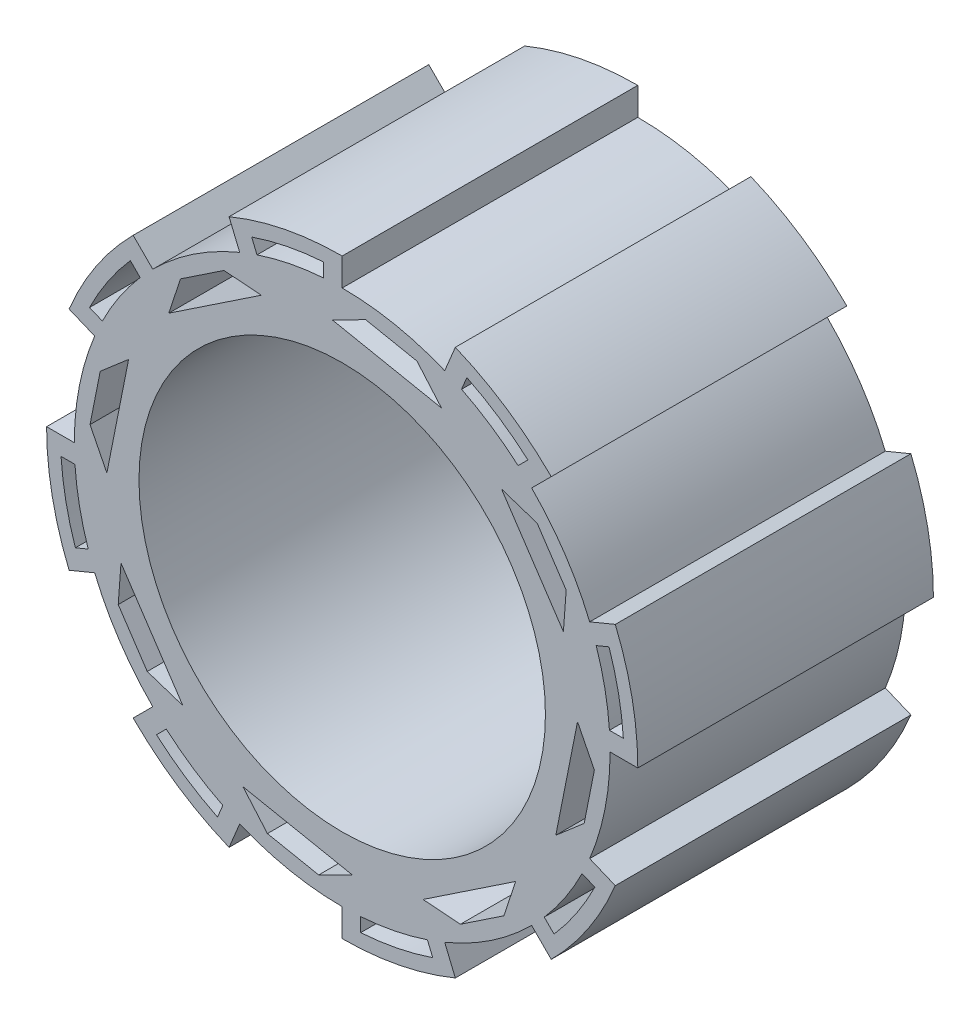
from build123d import *

# Parameters (mm, degrees)
BOSS_EXTRUDE1_DEPTH     = 80
SKETCH2_R               = 55
CUT_EXTRUDE1_DEPTH      = 67
CUT_EXTRUDE1_DEPTH_BACK = 127
CUT_EXTRUDE2_DEPTH      = 21
CUT_EXTRUDE2_DEPTH_BACK = 103
CUT_EXTRUDE3_DEPTH      = 36
CUT_EXTRUDE3_DEPTH_BACK = 105


with BuildPart() as part:
    # Base Drawing → Boss-Extrude1 (new body)
    with BuildSketch(Plane.XY):
        with BuildLine():
            Line((0, 72.5), (0, 80))
            ThreePointArc((0, 80), (-15.607225761, 78.462822432), (-30.614674589, 73.910362601))
            Line((-30.614674589, 73.910362601), (-27.744548846, 66.981266107))
            Line((-27.744548846, 66.981266107), (-25.632620818, 61.882620818))
            Line((-25.632620818, 61.882620818), (0, 0))
            Line((0, 0), (0, 72.5))
        make_face()
        with BuildLine():
            Line((-51.265241636, 51.265241636), (0, 0))
            Line((0, 0), (-25.632620818, 61.882620818))
            Line((-25.632620818, 61.882620818), (-27.744548846, 66.981266107))
            ThreePointArc((-27.744548846, 66.981266107), (-40.278841894, 60.281546892), (-51.265241636, 51.265241636))
        make_face()
        with BuildLine():
            Line((-61.882620818, 25.632620818), (0, 0))
            Line((0, 0), (-51.265241636, 51.265241636))
            Line((-51.265241636, 51.265241636), (-56.568542495, 56.568542495))
            ThreePointArc((-56.568542495, 56.568542495), (-66.517568984, 44.445618642), (-73.910362601, 30.614674589))
            Line((-73.910362601, 30.614674589), (-66.981266107, 27.744548846))
            Line((-66.981266107, 27.744548846), (-61.882620818, 25.632620818))
        make_face()
        with BuildLine():
            Line((-72.5, 0), (0, 0))
            Line((0, 0), (-61.882620818, 25.632620818))
            Line((-61.882620818, 25.632620818), (-66.981266107, 27.744548846))
            ThreePointArc((-66.981266107, 27.744548846), (-71.106932829, 14.144048346), (-72.5, 0))
        make_face()
        with BuildLine():
            Line((-61.882620818, -25.632620818), (0, 0))
            Line((0, 0), (-72.5, 0))
            Line((-72.5, 0), (-80, 0))
            ThreePointArc((-80, 0), (-78.462822432, -15.607225761), (-73.910362601, -30.614674589))
            Line((-73.910362601, -30.614674589), (-66.981266107, -27.744548846))
            Line((-66.981266107, -27.744548846), (-61.882620818, -25.632620818))
        make_face()
        with BuildLine():
            Line((-51.265241636, -51.265241636), (0, 0))
            Line((0, 0), (-61.882620818, -25.632620818))
            Line((-61.882620818, -25.632620818), (-66.981266107, -27.744548846))
            ThreePointArc((-66.981266107, -27.744548846), (-60.281546892, -40.278841894), (-51.265241636, -51.265241636))
        make_face()
        with BuildLine():
            Line((-25.632620818, -61.882620818), (0, 0))
            Line((0, 0), (-51.265241636, -51.265241636))
            Line((-51.265241636, -51.265241636), (-56.568542495, -56.568542495))
            ThreePointArc((-56.568542495, -56.568542495), (-44.445618642, -66.517568984), (-30.614674589, -73.910362601))
            Line((-30.614674589, -73.910362601), (-27.744548846, -66.981266107))
            Line((-27.744548846, -66.981266107), (-25.632620818, -61.882620818))
        make_face()
        with BuildLine():
            Line((0, -72.5), (0, 0))
            Line((0, 0), (-25.632620818, -61.882620818))
            Line((-25.632620818, -61.882620818), (-27.744548846, -66.981266107))
            ThreePointArc((-27.744548846, -66.981266107), (-14.144048346, -71.106932829), (0, -72.5))
        make_face()
        with BuildLine():
            Line((27.744548846, -66.981266107), (0, 0))
            Line((0, 0), (0, -72.5))
            Line((0, -72.5), (0, -80))
            ThreePointArc((0, -80), (15.607225761, -78.462822432), (30.614674589, -73.910362601))
            Line((30.614674589, -73.910362601), (27.744548846, -66.981266107))
        make_face()
        with BuildLine():
            Line((51.265241636, -51.265241636), (0, 0))
            Line((0, 0), (27.744548846, -66.981266107))
            ThreePointArc((27.744548846, -66.981266107), (40.278841894, -60.281546892), (51.265241636, -51.265241636))
        make_face()
        with BuildLine():
            Line((66.981266107, -27.744548846), (0, 0))
            Line((0, 0), (51.265241636, -51.265241636))
            Line((51.265241636, -51.265241636), (56.568542495, -56.568542495))
            ThreePointArc((56.568542495, -56.568542495), (66.517568984, -44.445618642), (73.910362601, -30.614674589))
            Line((73.910362601, -30.614674589), (66.981266107, -27.744548846))
        make_face()
        with BuildLine():
            Line((72.5, 0), (0, 0))
            Line((0, 0), (66.981266107, -27.744548846))
            ThreePointArc((66.981266107, -27.744548846), (71.106932829, -14.144048346), (72.5, 0))
        make_face()
        with BuildLine():
            Line((66.981266107, 27.744548846), (0, 0))
            Line((0, 0), (72.5, 0))
            Line((72.5, 0), (80, 0))
            ThreePointArc((80, 0), (78.462822432, 15.607225761), (73.910362601, 30.614674589))
            Line((73.910362601, 30.614674589), (66.981266107, 27.744548846))
        make_face()
        with BuildLine():
            Line((51.265241636, 51.265241636), (0, 0))
            Line((0, 0), (66.981266107, 27.744548846))
            ThreePointArc((66.981266107, 27.744548846), (60.281546892, 40.278841894), (51.265241636, 51.265241636))
        make_face()
        with BuildLine():
            Line((25.632620818, 61.882620818), (0, 0))
            Line((0, 0), (51.265241636, 51.265241636))
            Line((51.265241636, 51.265241636), (56.568542495, 56.568542495))
            ThreePointArc((56.568542495, 56.568542495), (44.445618642, 66.517568984), (30.614674589, 73.910362601))
            Line((30.614674589, 73.910362601), (27.744548846, 66.981266107))
            Line((27.744548846, 66.981266107), (25.632620818, 61.882620818))
        make_face()
        with BuildLine():
            ThreePointArc((27.744548846, 66.981266107), (14.144048346, 71.106932829), (0, 72.5))
            Line((0, 72.5), (0, 0))
            Line((0, 0), (25.632620818, 61.882620818))
            Line((25.632620818, 61.882620818), (27.744548846, 66.981266107))
        make_face()
    extrude(amount=BOSS_EXTRUDE1_DEPTH)

    # Sketch2 → Cut-Extrude1 (cut, two sides)
    with BuildSketch(Plane.XY.offset(80)) as cut_extrude1_sk:
        Circle(SKETCH2_R)
    extrude(amount=CUT_EXTRUDE1_DEPTH, mode=Mode.SUBTRACT)
    extrude(cut_extrude1_sk.sketch, amount=-CUT_EXTRUDE1_DEPTH_BACK, mode=Mode.SUBTRACT)

    # Sketch3 → Cut-Extrude2 (cut, two sides)
    with BuildSketch(Plane(origin=(0, 0, 0), x_dir=(-1, 0, 0), z_dir=(0, 0, -1))) as cut_extrude2_sk:
        with BuildLine():
            Line((-32.297887966, 64.908369514), (-32.363946509, 65.067848945))
            Line((-32.363946509, 65.067848945), (-33.156509848, 66.981266107))
            Line((-33.156509848, 66.981266107), (-33.736206807, 68.380778368))
            ThreePointArc((-33.736206807, 68.380778368), (-42.362230268, 63.399557938), (-50.265314136, 57.336381948))
            Line((-50.265314136, 57.336381948), (-49.203804332, 56.274872144))
            Line((-49.203804332, 56.274872144), (-47.72970773, 54.800775542))
            Line((-47.72970773, 54.800775542), (-47.607647458, 54.67871527))
            ThreePointArc((-47.607647458, 54.67871527), (-40.278841894, 60.281546892), (-32.297887966, 64.908369514))
        make_face()
        with BuildLine():
            Line((-68.735203838, 23.059092641), (-68.894683269, 23.125151184))
            Line((-68.894683269, 23.125151184), (-71.001371746, 23.997770123))
            Line((-71.001371746, 23.997770123), (-72.207612692, 24.497411482))
            ThreePointArc((-72.207612692, 24.497411482), (-74.784877631, 14.875637054), (-76.085888968, 5))
            Line((-76.085888968, 5), (-74.668691299, 5))
            Line((-74.668691299, 5), (-72.5, 5))
            Line((-72.5, 5), (-72.327380707, 5))
            ThreePointArc((-72.327380707, 5), (-71.106932829, 14.144048346), (-68.735203838, 23.059092641))
        make_face()
        with BuildLine():
            Line((-64.908369514, -32.297887966), (-65.067848945, -32.363946509))
            Line((-65.067848945, -32.363946509), (-66.981266107, -33.156509848))
            Line((-66.981266107, -33.156509848), (-68.363511265, -33.729054539))
            Line((-68.363511265, -33.729054539), (-68.380778368, -33.736206807))
            ThreePointArc((-68.380778368, -33.736206807), (-63.399557938, -42.362230268), (-57.336381948, -50.265314136))
            Line((-57.336381948, -50.265314136), (-56.25693439, -49.185866578))
            Line((-56.25693439, -49.185866578), (-54.800775542, -47.72970773))
            Line((-54.800775542, -47.72970773), (-54.67871527, -47.607647458))
            ThreePointArc((-54.67871527, -47.607647458), (-60.281546892, -40.278841894), (-64.908369514, -32.297887966))
        make_face()
        with BuildLine():
            ThreePointArc((-24.497411482, -72.207612692), (-14.875637054, -74.784877631), (-5, -76.085888968))
            Line((-5, -76.085888968), (-5, -75.365107954))
            Line((-5, -75.365107954), (-5, -74.464091379))
            Line((-5, -74.464091379), (-5, -72.5))
            Line((-5, -72.5), (-5, -72.327380707))
            ThreePointArc((-5, -72.327380707), (-14.144048346, -71.106932829), (-23.059092641, -68.735203838))
            Line((-23.059092641, -68.735203838), (-23.125151184, -68.894683269))
            Line((-23.125151184, -68.894683269), (-23.932515407, -70.843832926))
            Line((-23.932515407, -70.843832926), (-24.417934118, -72.015737361))
            Line((-24.417934118, -72.015737361), (-24.497411482, -72.207612692))
        make_face()
        with BuildLine():
            Line((48.47079588, -55.541863692), (47.72970773, -54.800775542))
            Line((47.72970773, -54.800775542), (47.607647458, -54.67871527))
            ThreePointArc((47.607647458, -54.67871527), (40.278841894, -60.281546892), (32.297887966, -64.908369514))
            Line((32.297887966, -64.908369514), (32.363946509, -65.067848945))
            Line((32.363946509, -65.067848945), (32.936166208, -66.449309504))
            Line((32.936166208, -66.449309504), (33.603941902, -68.061462639))
            Line((33.603941902, -68.061462639), (33.736206807, -68.380778368))
            ThreePointArc((33.736206807, -68.380778368), (42.362230268, -63.399557938), (50.265314136, -57.336381948))
            Line((50.265314136, -57.336381948), (48.47079588, -55.541863692))
        make_face()
        with BuildLine():
            Line((75.823779763, -5), (72.5, -5))
            Line((72.5, -5), (72.337295851, -5))
            Line((72.337295851, -5), (72.327380707, -5))
            ThreePointArc((72.327380707, -5), (71.106932829, -14.144048346), (68.735203838, -23.059092641))
            Line((68.735203838, -23.059092641), (68.894683269, -23.125151184))
            Line((68.894683269, -23.125151184), (69.253006962, -23.273573717))
            Line((69.253006962, -23.273573717), (70.382632906, -23.741480104))
            Line((70.382632906, -23.741480104), (72.207612692, -24.497411482))
            ThreePointArc((72.207612692, -24.497411482), (74.784877631, -14.875637054), (76.085888968, -5))
            Line((76.085888968, -5), (75.823779763, -5))
        make_face()
        with BuildLine():
            Line((56.184348869, 49.113281057), (54.800775542, 47.72970773))
            Line((54.800775542, 47.72970773), (54.679998373, 47.608930561))
            Line((54.679998373, 47.608930561), (54.67871527, 47.607647458))
            ThreePointArc((54.67871527, 47.607647458), (60.281546892, 40.278841894), (64.908369514, 32.297887966))
            Line((64.908369514, 32.297887966), (65.067848945, 32.363946509))
            Line((65.067848945, 32.363946509), (65.431620873, 32.514625775))
            Line((65.431620873, 32.514625775), (66.336433936, 32.889411617))
            Line((66.336433936, 32.889411617), (68.380778368, 33.736206807))
            ThreePointArc((68.380778368, 33.736206807), (63.399557938, 42.362230268), (57.336381948, 50.265314136))
            Line((57.336381948, 50.265314136), (56.184348869, 49.113281057))
        make_face()
        with BuildLine():
            Line((23.059092641, 68.735203838), (23.125151184, 68.894683269))
            Line((23.125151184, 68.894683269), (24.132904336, 71.327614596))
            Line((24.132904336, 71.327614596), (24.497411482, 72.207612692))
            ThreePointArc((24.497411482, 72.207612692), (14.875637054, 74.784877631), (5, 76.085888968))
            Line((5, 76.085888968), (5, 74.952220789))
            Line((5, 74.952220789), (5, 72.5))
            Line((5, 72.5), (5, 72.327380707))
            ThreePointArc((5, 72.327380707), (14.144048346, 71.106932829), (23.059092641, 68.735203838))
        make_face()
    extrude(amount=CUT_EXTRUDE2_DEPTH, mode=Mode.SUBTRACT)
    extrude(cut_extrude2_sk.sketch, amount=-CUT_EXTRUDE2_DEPTH_BACK, mode=Mode.SUBTRACT)

    # Sketch5 → Cut-Extrude3 (cut, two sides)
    with BuildSketch(Plane(origin=(0, 0, 0), x_dir=(-1, 0, 0), z_dir=(0, 0, -1))) as cut_extrude3_sk:
        Polygon((-55.940927069, 27.758983606), (-54.251958897, 36.25), (-60.616612502, 31.997274423), (-59.869933187, 21.878810409), align=None)
        Polygon((-47.053622778, 41.059774423), (-54.251958897, 36.25), (-55.940927069, 27.758983606), align=None)
        Polygon((-43.12461666, 46.939947621), (-52.758600266, 43.757620818), (-54.251958897, 36.25), (-47.053622778, 41.059774423), align=None)
        Polygon((-54.251958897, 36.25), (-52.758600266, 43.757620818), (-60.616612502, 31.997274423), align=None)
        Polygon((-12.72930721, 63.994548846), (-20.236928028, 65.487907477), (-26.863780541, 57.80509095), (-19.927643329, 59.184774423), align=None)
        Polygon((-6.364653605, 68.247274423), (-20.236928028, 65.487907477), (-12.72930721, 63.994548846), align=None)
        Polygon((-6.364653605, 68.247274423), (-12.72930721, 63.994548846), (-4.238290817, 62.305580674), (2.697846395, 63.685264147), align=None)
        Polygon((-4.238290817, 62.305580674), (-12.72930721, 63.994548846), (-19.927643329, 59.184774423), align=None)
        Polygon((36.25, 54.251958897), (31.997274423, 60.616612502), (21.878810409, 59.869933187), (27.758983606, 55.940927069), align=None)
        Polygon((34.409379015, 51.497274923), (36.25, 54.251958897), (27.758983606, 55.940927069), align=None)
        Polygon((43.757620818, 52.758600266), (36.25, 54.251958897), (41.059774423, 47.053622778), (46.939947621, 43.12461666), align=None)
        Polygon((37.877447621, 56.687606384), (36.25, 54.251958897), (43.757620818, 52.758600266), align=None)
        Polygon((37.877447621, 56.687606384), (31.997274423, 60.616612502), (36.25, 54.251958897), align=None)
        Polygon((41.059774423, 47.053622778), (36.25, 54.251958897), (34.409379015, 51.497274923), align=None)
        Polygon((68.247274423, 6.364653605), (63.994548846, 12.72930721), (62.305580674, 4.238290817), (63.685264147, -2.697846395), align=None)
        Polygon((63.994548846, 12.72930721), (59.184774423, 19.927643329), (62.305580674, 4.238290817), align=None)
        Polygon((63.994548846, 12.72930721), (65.487907477, 20.236928028), (57.80509095, 26.863780541), (59.184774423, 19.927643329), align=None)
        Polygon((66.86759095, 13.300790817), (65.487907477, 20.236928028), (63.994548846, 12.72930721), align=None)
        Polygon((66.86759095, 13.300790817), (63.994548846, 12.72930721), (68.247274423, 6.364653605), align=None)
        Polygon((56.687606384, -37.877447621), (54.251958897, -36.25), (52.758600266, -43.757620818), align=None)
        Polygon((56.687606384, -37.877447621), (60.616612502, -31.997274423), (54.251958897, -36.25), align=None)
        Polygon((54.251958897, -36.25), (60.616612502, -31.997274423), (59.869933187, -21.878810409), (55.940927069, -27.758983606), align=None)
        Polygon((54.251958897, -36.25), (55.940927069, -27.758983606), (47.053622778, -41.059774423), align=None)
        Polygon((52.758600266, -43.757620818), (54.251958897, -36.25), (47.053622778, -41.059774423), (43.12461666, -46.939947621), align=None)
        Polygon((-2.697846395, -63.685264147), (6.364653605, -68.247274423), (12.72930721, -63.994548846), (4.238290817, -62.305580674), align=None)
        Polygon((12.72930721, -63.994548846), (6.364653605, -68.247274423), (13.300790817, -66.86759095), align=None)
        Polygon((20.236928028, -65.487907477), (12.72930721, -63.994548846), (13.300790817, -66.86759095), align=None)
        Polygon((19.927643329, -59.184774423), (12.72930721, -63.994548846), (20.236928028, -65.487907477), (26.863780541, -57.80509095), align=None)
        Polygon((19.927643329, -59.184774423), (4.238290817, -62.305580674), (12.72930721, -63.994548846), align=None)
        Polygon((-46.939947621, -43.12461666), (-43.757620818, -52.758600266), (-36.25, -54.251958897), (-41.059774423, -47.053622778), align=None)
        Polygon((-36.25, -54.251958897), (-43.757620818, -52.758600266), (-37.877447621, -56.687606384), align=None)
        Polygon((-31.997274423, -60.616612502), (-36.25, -54.251958897), (-37.877447621, -56.687606384), align=None)
        Polygon((-27.758983606, -55.940927069), (-36.25, -54.251958897), (-31.997274423, -60.616612502), (-21.878810409, -59.869933187), align=None)
        Polygon((-41.059774423, -47.053622778), (-36.25, -54.251958897), (-27.758983606, -55.940927069), align=None)
        Polygon((-63.685264147, 2.697846395), (-68.247274423, -6.364653605), (-63.994548846, -12.72930721), (-62.305580674, -4.238290817), align=None)
        Polygon((-63.994548846, -12.72930721), (-68.247274423, -6.364653605), (-65.487907477, -20.236928028), align=None)
        Polygon((-59.184774423, -19.927643329), (-63.994548846, -12.72930721), (-65.487907477, -20.236928028), (-57.80509095, -26.863780541), align=None)
        Polygon((-62.305580674, -4.238290817), (-63.994548846, -12.72930721), (-59.184774423, -19.927643329), align=None)
    extrude(amount=CUT_EXTRUDE3_DEPTH, mode=Mode.SUBTRACT)
    extrude(cut_extrude3_sk.sketch, amount=-CUT_EXTRUDE3_DEPTH_BACK, mode=Mode.SUBTRACT)


solid = part.part
